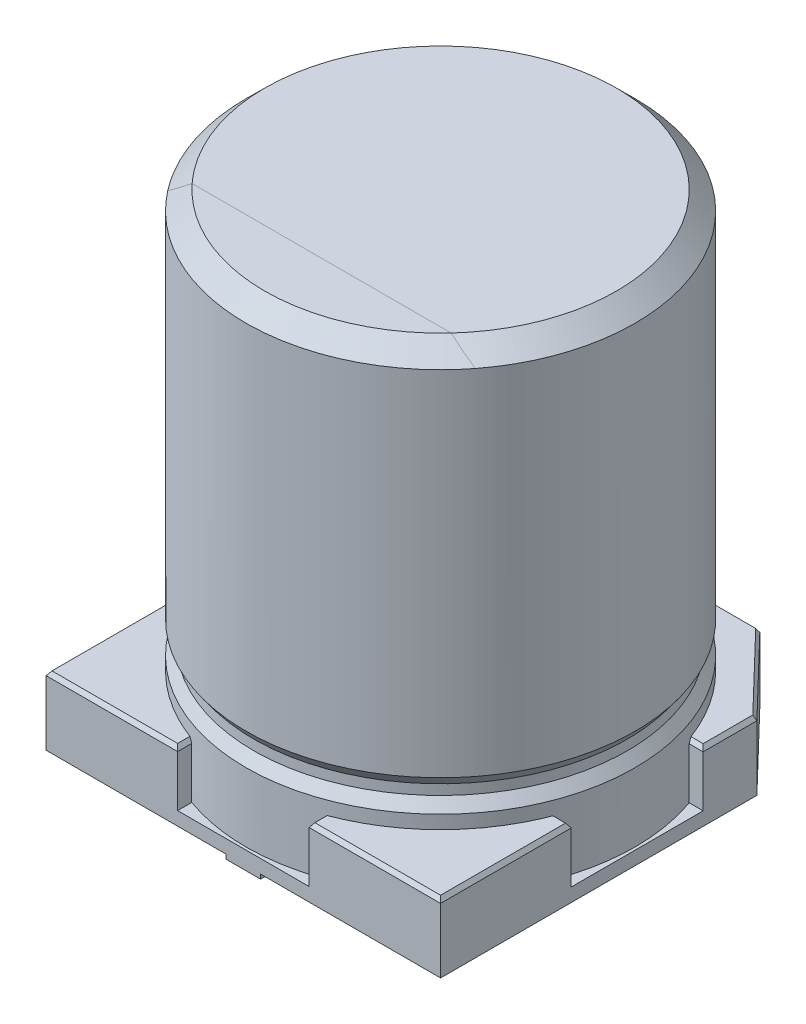
from build123d import *

# Parameters (mm, degrees)
BOSS_EXTRUDE1_DEPTH = 0.1571
BOSS_EXTRUDE2_DEPTH = 0.6443
CHAMFER1_SIZE       = 0.0487
BOSS_EXTRUDE3_START = -0.1571
BOSS_EXTRUDE3_DEPTH = 0.0514
SKETCH2_R           = 3.27
BOSS_EXTRUDE4_DEPTH = 5.5
CHAMFER2_SIZE       = 0.2155
CHAMFER2_SIZE2      = 0.314
SCALE1_SCALE_X      = 0.651376147
SCALE1_SCALE_Y      = 0.939929329
SCALE1_SCALE_Z      = 0.651376147


with BuildPart() as part:
    # Sketch1 → Boss-Extrude1 (new body)
    with BuildSketch(Plane(origin=(0, 0, 0), x_dir=(1, 0, 0), z_dir=(0, 1, 0))):
        Polygon((-1.115015984, 1.105000019), (-1.120023966, 3.314999898), (-2.051918983, 3.314999898), (-3.314999898, 2.002368291), (-3.314999898, 1.098344008), align=None)
        Polygon((0, -1.592377345), (0, 1.592377345), (-0.288244069, 1.592377345), (-0.28754435, 3.314999898), (-1.120023966, 3.314999898), (-1.115015984, 1.105000019), (-3.314999898, 1.098344008), (-3.314999898, -1.118712743), (-1.110008001, -1.105000019), (-1.105000019, -3.314999898), (-0.289643526, -3.314999898), (-0.288943807, -1.592377345), align=None)
        Polygon((-3.314999898, -3.314999898), (-1.105000019, -3.314999898), (-1.110008001, -1.105000019), (-3.314999898, -1.118712743), align=None)
        Polygon((0.288943807, -1.592377345), (0, -1.592377345), (0, -3.314999898), (0.289643526, -3.314999898), align=None)
        Polygon((0, -3.314999898), (0, -1.592377345), (-0.288943807, -1.592377345), (-0.289643526, -3.314999898), align=None)
        Polygon((0, 1.592377345), (0, 3.314999898), (-0.28754435, 3.314999898), (-0.288244069, 1.592377345), align=None)
        Polygon((0.28754435, 3.314999898), (0, 3.314999898), (0, 1.592377345), (0.288244069, 1.592377345), align=None)
        Polygon((0.288244069, 1.592377345), (0, 1.592377345), (0, -1.592377345), (0.288943807, -1.592377345), (0.289643526, -3.314999898), (1.105000019, -3.314999898), (1.110008001, -1.10500002), (3.314999898, -1.118712743), (3.314999898, 1.098344008), (1.115015984, 1.105000019), (1.120023966, 3.314999898), (0.28754435, 3.314999898), align=None)
        Polygon((2.051671346, 3.314999898), (1.120023966, 3.314999898), (1.115015984, 1.105000019), (3.314999898, 1.098344008), (3.314999898, 2.002368291), align=None)
        Polygon((1.110008001, -1.10500002), (1.105000019, -3.314999898), (3.314999898, -3.314999898), (3.314999898, -1.118712743), align=None)
    extrude(amount=-BOSS_EXTRUDE1_DEPTH)

    # Sketch1_4 → Boss-Extrude2 (add)
    with BuildSketch(Plane(origin=(0, 0, 0), x_dir=(1, 0, 0), z_dir=(0, 1, 0))):
        Polygon((-1.115015984, 1.105000019), (-1.120023966, 3.314999898), (-2.051918983, 3.314999898), (-3.314999898, 2.002368291), (-3.314999898, 1.098344008), align=None)
        Polygon((-3.314999898, -3.314999898), (-1.105000019, -3.314999898), (-1.110008001, -1.105000019), (-3.314999898, -1.118712743), align=None)
        Polygon((1.115015984, 1.105000019), (3.314999898, 1.098344008), (3.314999898, 2.002368291), (2.051671346, 3.314999898), (1.120023966, 3.314999898), align=None)
        Polygon((1.105000019, -3.314999898), (3.314999898, -3.314999898), (3.314999898, -1.118712743), (1.110008001, -1.10500002), align=None)
    extrude(amount=BOSS_EXTRUDE2_DEPTH)

    # Chamfer1
    chamfer1_edges = [part.edges().sort_by_distance(p)[0] for p in [
        (2.212503949, 0.6443, 1.111856381),
        (3.314999898, 0.6443, 2.216856321),
        (2.209999959, 0.6443, 3.314999898),
        (1.10750401, 0.6443, 2.209999959),
        (1.117519975, 0.6443, -2.209999959),
        (1.585847656, 0.6443, -3.314999898),
        (2.683335622, 0.6443, -2.658684095),
        (3.314999898, 0.6443, -1.55035615),
        (2.215007941, 0.6443, -1.101672014),
        (-2.215007941, 0.6443, -1.101672014),
        (-3.314999898, 0.6443, -1.55035615),
        (-2.683459441, 0.6443, -2.658684095),
        (-1.585971475, 0.6443, -3.314999898),
        (-1.117519975, 0.6443, -2.209999959),
        (-2.209999959, 0.6443, 3.314999898),
        (-3.314999898, 0.6443, 2.216856321),
        (-2.21250395, 0.6443, 1.111856381),
        (-1.10750401, 0.6443, 2.209999959),
    ]]
    chamfer(chamfer1_edges, length=CHAMFER1_SIZE)

    # Sketch1_5 → Boss-Extrude3 (add)
    with BuildSketch(Plane(origin=(0, 0, 0), x_dir=(1, 0, 0), z_dir=(0, 1, 0)).offset(BOSS_EXTRUDE3_START)):
        Polygon((0, -3.314999898), (0, -1.592377345), (-0.288943807, -1.592377345), (-0.289643526, -3.314999898), align=None)
        Polygon((0.288943807, -1.592377345), (0, -1.592377345), (0, -3.314999898), (0.289643526, -3.314999898), align=None)
        Polygon((0, 1.592377345), (0, 3.314999898), (-0.28754435, 3.314999898), (-0.288244069, 1.592377345), align=None)
        Polygon((0.28754435, 3.314999898), (0, 3.314999898), (0, 1.592377345), (0.288244069, 1.592377345), align=None)
    extrude(amount=-BOSS_EXTRUDE3_DEPTH)

    # Sketch2 → Boss-Extrude4 (add)
    with BuildSketch(Plane(origin=(0, 0, 0), x_dir=(1, 0, 0), z_dir=(0, 1, 0))):
        with Locations(Location((0, 0, 0), (0, 0, 69.980077841))):
            Circle(SKETCH2_R)
    extrude(amount=BOSS_EXTRUDE4_DEPTH)

    # Chamfer2
    chamfer2_edges = [part.edges().sort_by_distance(p)[0] for p in [
        (-1.119474234, 5.5, 3.072405806),
    ]]
    chamfer2_side = [part.faces().sort_by_distance(p)[0] for p in [
        (-1.119474234, 2.75, 3.072405806),
    ]]
    chamfer(chamfer2_edges, length=CHAMFER2_SIZE, length2=CHAMFER2_SIZE2, reference=chamfer2_side[0])

    # Sketch3 → Cut-Revolve1 (revolve, cut)
    with BuildSketch(Plane.XY, mode=Mode.PRIVATE) as cut_revolve1_sk:
        Polygon((3.1392, 1.0429), (3.1392, 0.9251), (3.27, 0.8), (3.27, 1.168), align=None)
    revolve(cut_revolve1_sk.sketch.rotate(Axis((0, 5.2845, 0), (0, -1, 0)), 290.019922159), axis=Axis((0, 5.2845, 0), (0, -1, 0)), mode=Mode.SUBTRACT)


with BuildPart() as part_1:
    # Scale1: scaled about (-1.649e-06, 2.586934831, 0.01960128)
    add(part.part.scale((SCALE1_SCALE_X, SCALE1_SCALE_Y, SCALE1_SCALE_Z), about=(-1.649e-06, 2.586934831, 0.01960128)))


solid = part_1.part
